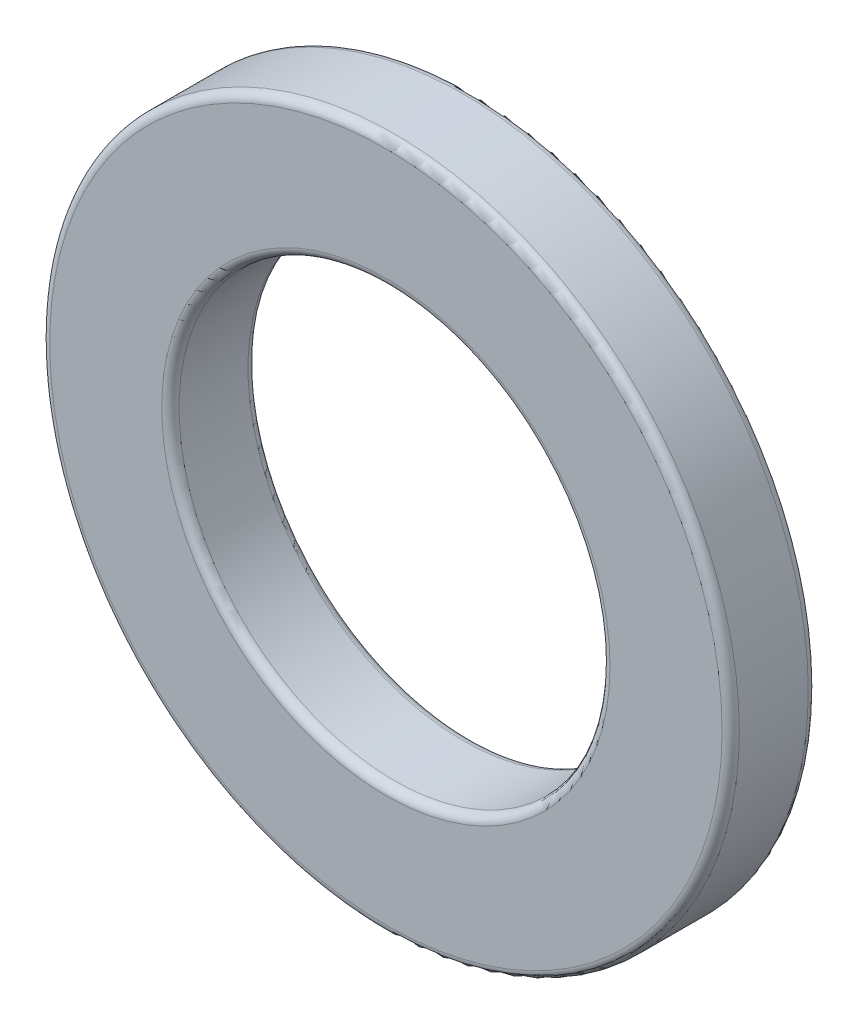
from build123d import *

# Parameters (mm, degrees)
SKETCH1_R           = 4
SKETCH1_R_2         = 2.5
BOSS_EXTRUDE1_DEPTH = 1
FILLET1_R           = 0.1


with BuildPart() as part:
    # Sketch1 → Boss-Extrude1 (new body)
    with BuildSketch(Plane.XY):
        Circle(SKETCH1_R)
        Circle(SKETCH1_R_2, mode=Mode.SUBTRACT)
    extrude(amount=BOSS_EXTRUDE1_DEPTH)

    # Fillet1
    fillet1_edges = [part.edges().sort_by_distance(p)[0] for p in [
        (-4, 0, 0),
        (-4, 0, 1),
        (-2.5, 0, 0),
        (-2.5, 0, 1),
    ]]
    fillet(fillet1_edges, radius=FILLET1_R)


solid = part.part
